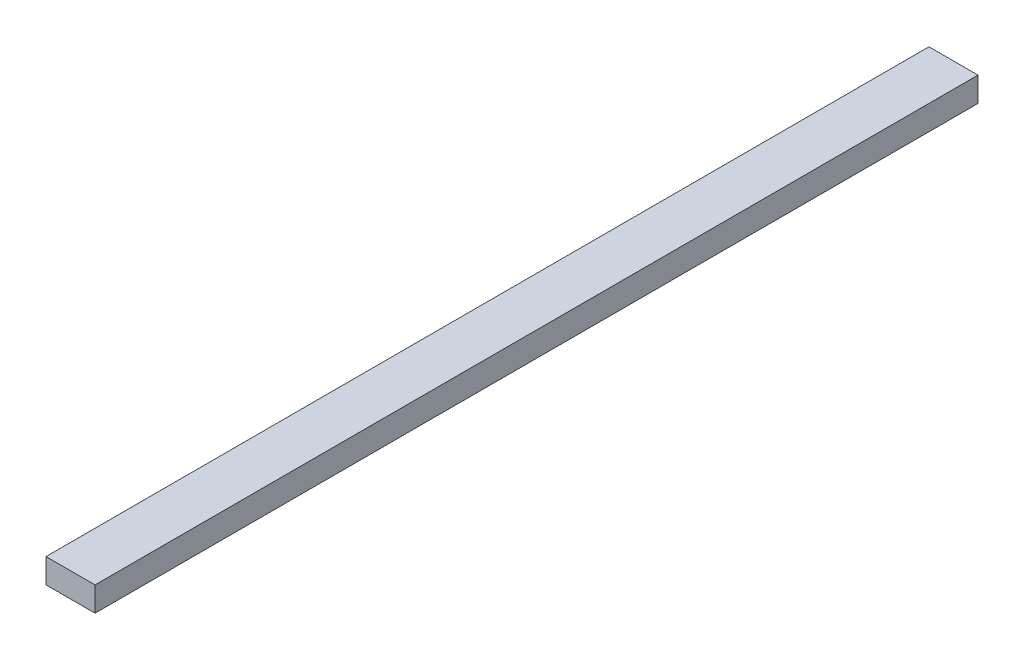
from build123d import *

# Parameters (mm, degrees)
SKETCH1_W           = 50.8
SKETCH1_H           = 25.4
BOSS_EXTRUDE1_DEPTH = 914.4


with BuildPart() as part:
    # Sketch1 → Boss-Extrude1 (new body)
    with BuildSketch(Plane.XY):
        Rectangle(SKETCH1_W, SKETCH1_H)
    extrude(amount=BOSS_EXTRUDE1_DEPTH)


solid = part.part
